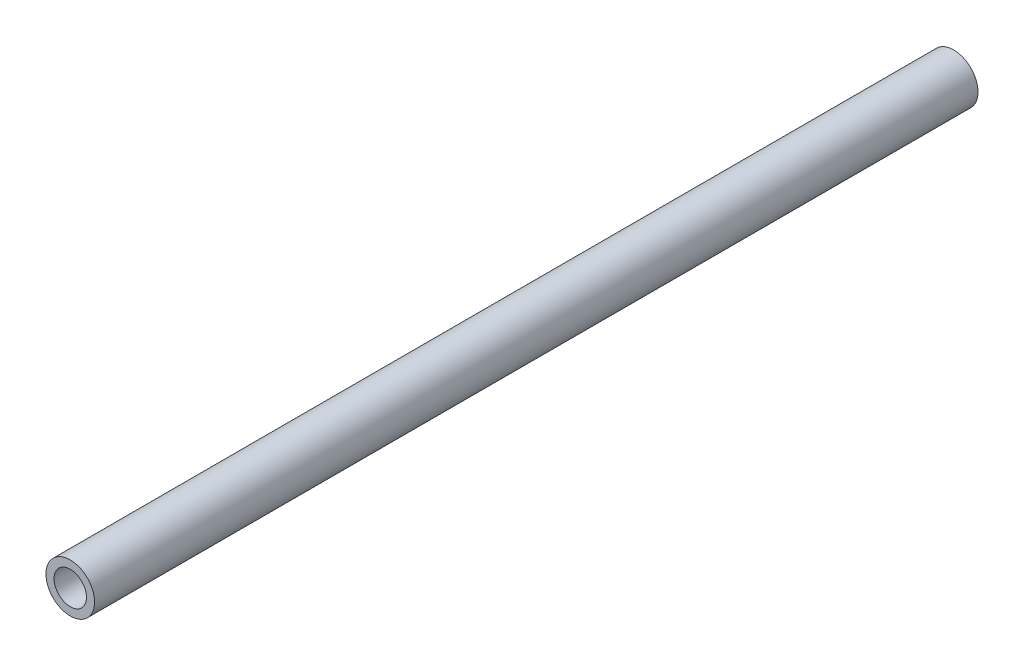
from build123d import *

# Parameters (mm, degrees)
SKETCH1_R           = 3
SKETCH1_R_2         = 2
BOSS_EXTRUDE1_DEPTH = 109


with BuildPart() as part:
    # Sketch1 → Boss-Extrude1 (new body)
    with BuildSketch(Plane.XY):
        Circle(SKETCH1_R)
        Circle(SKETCH1_R_2, mode=Mode.SUBTRACT)
    extrude(amount=BOSS_EXTRUDE1_DEPTH)


solid = part.part
